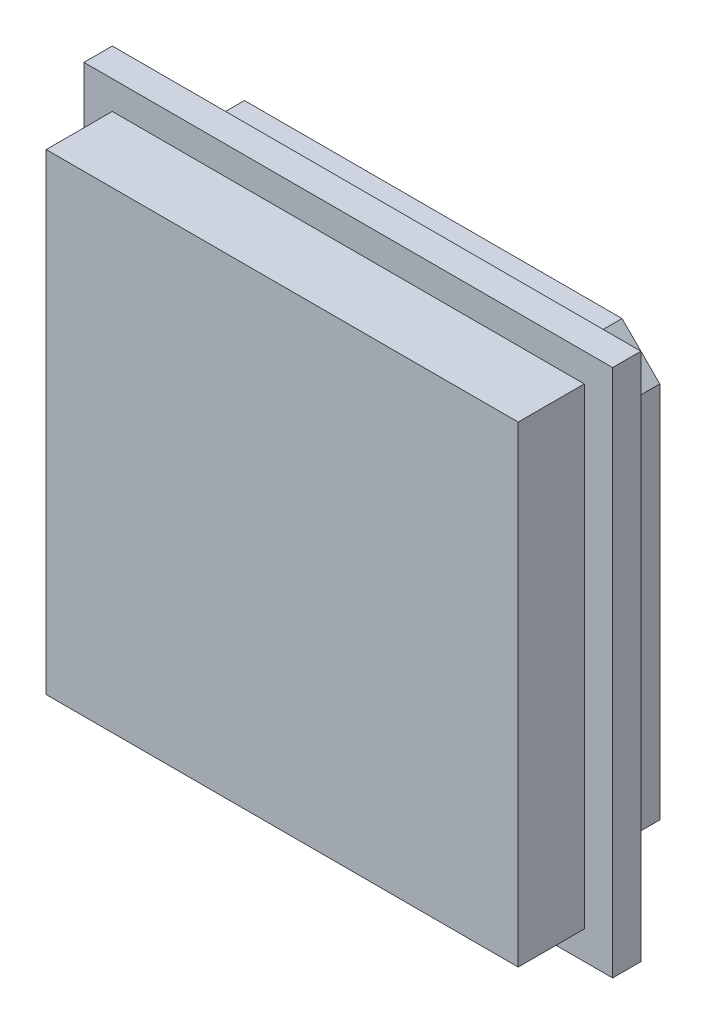
from build123d import *

# Parameters (mm, degrees)
BOSS_EXTRUDE1_DEPTH = 3
SKETCH2_W           = 28
SKETCH2_H           = 28
BOSS_EXTRUDE2_DEPTH = 1.5
SKETCH3_W           = 25
SKETCH3_H           = 25
BOSS_EXTRUDE3_DEPTH = 3.5


with BuildPart() as part:
    # Sketch1 → Boss-Extrude1 (new body)
    with BuildSketch(Plane.XY):
        Polygon((-166.007283518, 36), (-186.007283518, 36), (-188.007283518, 34), (-188.007283518, 14), (-186.007283518, 12), (-166.007283518, 12), (-164.007283518, 14), (-164.007283518, 34), align=None)
    extrude(amount=BOSS_EXTRUDE1_DEPTH)

    # Sketch2 → Boss-Extrude2 (add)
    with BuildSketch(Plane.XY.offset(3)):
        with Locations((-176.007283518, 24)):
            Rectangle(SKETCH2_W, SKETCH2_H)
    extrude(amount=BOSS_EXTRUDE2_DEPTH)

    # Sketch3 → Boss-Extrude3 (add)
    with BuildSketch(Plane.XY.offset(4.5)):
        with Locations((-176.007283518, 24)):
            Rectangle(SKETCH3_W, SKETCH3_H)
    extrude(amount=BOSS_EXTRUDE3_DEPTH)


solid = part.part
